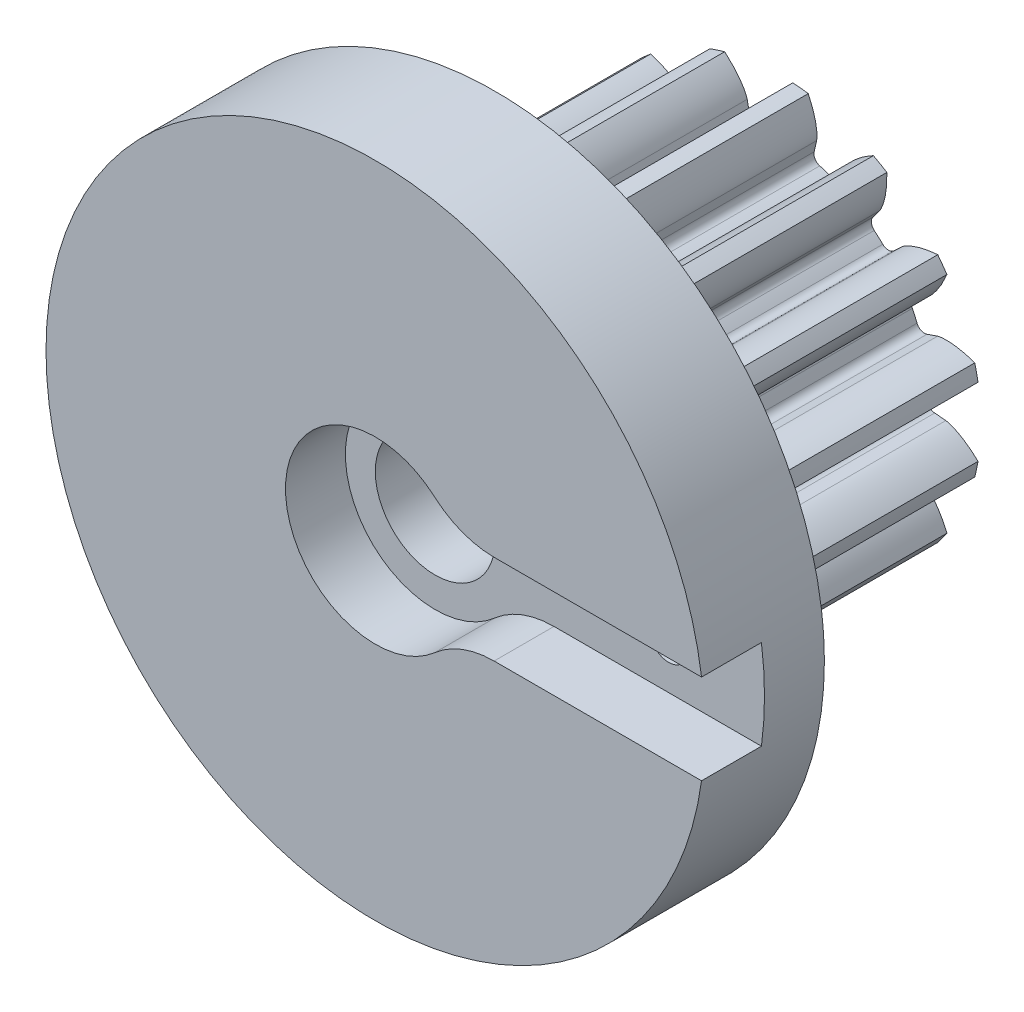
from build123d import *

# Parameters (mm, degrees)
SKETCH3_R                = 8.995833333
BOSS_EXTRUDE1_DEPTH      = 12.7
CUT_EXTRUDE1_DEPTH       = 18.976096204
FILLET1_R                = 0.355076163
CIRPATTERN1_COUNT        = 15
FILLET1_OF_CIRPATTERN1_R = 0.355076163
SCALE1_SCALE             = 1.9
SKETCH12_R               = 27.94
BOSS_EXTRUDE3_DEPTH      = 10.16
SKETCH13_R               = 5.08
CUT_EXTRUDE6_DEPTH       = 53.317221147
CUT_EXTRUDE7_DEPTH       = 5.08
SKETCH15_R               = 1.5875
CUT_EXTRUDE8_DEPTH       = 5.08
SKETCH16_R               = 2.74955
CUT_EXTRUDE9_DEPTH       = 3.81


with BuildPart() as part:
    # Sketch3 → Boss-Extrude1 (new body)
    with BuildSketch(Plane.XY):
        Circle(SKETCH3_R)
    extrude(amount=-BOSS_EXTRUDE1_DEPTH)

    # Sketch4 → Cut-Extrude1 (cut, symmetric)
    with BuildSketch(Plane.XY):
        with BuildLine():
            Line((6.587922, 0.593292844), (7.428746027, 0.669015489))
            add(Edge.make_bspline(
                [(7.428746027, 0.669015489), (7.431239529, 0.669275952), (7.438221543, 0.670116627), (7.45137303, 0.672140658), (7.47274968, 0.676058941), (7.499853291, 0.681954394), (7.534710401, 0.690607559), (7.575527841, 0.702125727), (7.620103171, 0.716165985), (7.668268726, 0.7329259), (7.716008275, 0.750953862), (7.763320815, 0.770148726), (7.810159557, 0.790358577), (7.866530888, 0.816118543), (7.933604431, 0.848781677), (8.011190656, 0.889523955), (8.098185635, 0.938742517), (8.185706836, 0.992089652), (8.27086582, 1.04719041), (8.355732614, 1.105822875), (8.437008174, 1.164648852), (8.520142822, 1.228735923), (8.59623198, 1.289414256), (8.679980615, 1.360650951), (8.747135157, 1.419094683), (8.815206291, 1.48214701), (8.84814287, 1.513228673), (8.864892817, 1.529278494)],
                knots=[0, 0, 0, 0, 0, 0.005376749, 0.015083688, 0.02853182, 0.04661014, 0.064854849, 0.092110525, 0.119476176, 0.146842496, 0.174208854, 0.201574956, 0.228941013, 0.256307345, 0.307035032, 0.361767352, 0.416499661, 0.471231937, 0.525964282, 0.580696616, 0.635428982, 0.690161387, 0.744893688, 0.799626082, 0.854358408, 0.909090915, 0.909090915, 0.909090915, 0.909090915, 0.909090915], degree=4))
            ThreePointArc((8.864892817, 1.529278494), (8.995833333, 0), (8.864892817, -1.529278494))
            add(Edge.make_bspline(
                [(7.428746027, -0.669015489), (7.431239529, -0.669275952), (7.438221543, -0.670116627), (7.45137303, -0.672140658), (7.47274968, -0.676058941), (7.499853291, -0.681954394), (7.534710401, -0.690607559), (7.575527841, -0.702125727), (7.620103171, -0.716165985), (7.668268726, -0.7329259), (7.716008275, -0.750953862), (7.763320815, -0.770148726), (7.810159557, -0.790358577), (7.866530888, -0.816118543), (7.933604431, -0.848781677), (8.011190656, -0.889523955), (8.098185635, -0.938742517), (8.185706836, -0.992089652), (8.27086582, -1.04719041), (8.355732614, -1.105822875), (8.437008174, -1.164648852), (8.520142822, -1.228735923), (8.59623198, -1.289414256), (8.679980615, -1.360650951), (8.747135157, -1.419094683), (8.815206291, -1.48214701), (8.84814287, -1.513228673), (8.864892817, -1.529278494)],
                knots=[0, 0, 0, 0, 0, 0.005376749, 0.015083688, 0.02853182, 0.04661014, 0.064854849, 0.092110525, 0.119476176, 0.146842496, 0.174208854, 0.201574956, 0.228941013, 0.256307345, 0.307035032, 0.361767352, 0.416499661, 0.471231937, 0.525964282, 0.580696616, 0.635428982, 0.690161387, 0.744893688, 0.799626082, 0.854358408, 0.909090915, 0.909090915, 0.909090915, 0.909090915, 0.909090915], degree=4))
            Line((7.428746027, -0.669015489), (6.587922, -0.593292844))
            ThreePointArc((6.587922, -0.593292844), (6.614583333, 0), (6.587922, 0.593292844))
        make_face()
    cut_extrude1 = extrude(amount=CUT_EXTRUDE1_DEPTH, both=True, mode=Mode.SUBTRACT)

    # Fillet1
    fillet1_edges = [part.edges().sort_by_distance(p)[0] for p in [
        (6.587922, -0.593292844, -6.35),
        (6.587922, 0.593292844, -6.35),
    ]]
    fillet(fillet1_edges, radius=FILLET1_R)

    # CirPattern1: Cut-Extrude1 ×15 about axis
    cirpattern1_axis = Axis((0, 0, 6.35), (0, 0, -1))
    for i in range(1, CIRPATTERN1_COUNT):
        add(cut_extrude1.rotate(cirpattern1_axis, i * 360 / CIRPATTERN1_COUNT), mode=Mode.SUBTRACT)

    # Fillet1 of CirPattern1
    fillet1_of_cirpattern1_edges = [part.edges().sort_by_distance(p)[0] for p in [
        (5.777052279, -3.221549262, -6.35),
        (6.259680158, -2.137549296, -6.35),
        (3.967277735, -5.292770545, -6.35),
        (4.849082749, -4.498789744, -6.35),
        (1.47152483, -6.448823718, -6.35),
        (2.600034881, -6.082148575, -6.35),
        (-1.278668086, -6.489816685, -6.35),
        (-0.098582639, -6.613848663, -6.35),
        (-3.807767675, -5.408661388, -6.35),
        (-2.780154325, -6.001954232, -6.35),
        (-5.678469639, -3.392299401, -6.35),
        (-4.981012072, -4.352267388, -6.35),
        (-6.567312616, -0.78937803, -6.35),
        (-6.32060758, -1.950033974, -6.35),
        (-6.32060758, 1.950033974, -6.35),
        (-6.567312616, 0.78937803, -6.35),
        (-4.981012072, 4.352267388, -6.35),
        (-5.678469639, 3.392299401, -6.35),
        (-2.780154325, 6.001954232, -6.35),
        (-3.807767675, 5.408661388, -6.35),
        (-0.098582639, 6.613848663, -6.35),
        (-1.278668086, 6.489816685, -6.35),
        (2.600034881, 6.082148575, -6.35),
        (1.47152483, 6.448823718, -6.35),
        (4.849082749, 4.498789744, -6.35),
        (3.967277735, 5.292770545, -6.35),
        (6.259680158, 2.137549296, -6.35),
        (5.777052279, 3.221549262, -6.35),
    ]]
    fillet(fillet1_of_cirpattern1_edges, radius=FILLET1_OF_CIRPATTERN1_R)


with BuildPart() as part_1:
    # Scale1: scaled about (0, 0, -6.349999528)
    add(part.part.scale(SCALE1_SCALE).moved(Location((0, 0, 5.714999575))))


with BuildPart() as boss_extrude3_tool:
    # Sketch12 → Boss-Extrude3 (new body)
    with BuildSketch(Plane.XY.offset(5.715004103)):
        Circle(SKETCH12_R)
    extrude(amount=BOSS_EXTRUDE3_DEPTH)


with BuildPart() as part_2:
    add(part_1.part)


with BuildPart() as part_3:
    # Boss-Extrude3: joined with boss_extrude3_tool
    add(part_2.part.fuse(boss_extrude3_tool.part, tol=0.00001))

    # Sketch13 → Cut-Extrude6 (cut, through all)
    with BuildSketch(Plane.XY.offset(15.875004103)):
        Circle(SKETCH13_R)
    extrude(amount=-CUT_EXTRUDE6_DEPTH, mode=Mode.SUBTRACT)

    # Sketch14 → Cut-Extrude7 (cut)
    with BuildSketch(Plane.XY.offset(15.875004103)):
        with BuildLine():
            Line((10.080312495, 3.81), (29.344687406, 3.81))
            Line((29.344687406, 3.81), (29.344687406, -3.81))
            Line((29.344687406, -3.81), (10.080312495, -3.81))
            ThreePointArc((10.080312495, -3.81), (7.386235659, -4.302142678), (5.040156248, -5.715))
            ThreePointArc((5.040156248, -5.715), (-7.62, 0), (5.040156248, 5.715))
            ThreePointArc((5.040156248, 5.715), (7.386235659, 4.302142678), (10.080312495, 3.81))
        make_face()
    extrude(amount=-CUT_EXTRUDE7_DEPTH, mode=Mode.SUBTRACT)

    # Sketch15 → Cut-Extrude8 (cut)
    with BuildSketch(Plane.XY.offset(10.795004103)):
        with Locations((19.812, 0)):
            Circle(SKETCH15_R)
    extrude(amount=-CUT_EXTRUDE8_DEPTH, mode=Mode.SUBTRACT)

    # Sketch16 → Cut-Extrude9 (cut)
    with BuildSketch(Plane(origin=(0, 0, 5.715004103), x_dir=(-1, 0, 0), z_dir=(0, 0, -1))):
        with Locations((-19.812, 0)):
            Circle(SKETCH16_R)
    extrude(amount=-CUT_EXTRUDE9_DEPTH, mode=Mode.SUBTRACT)


solid = part_3.part
